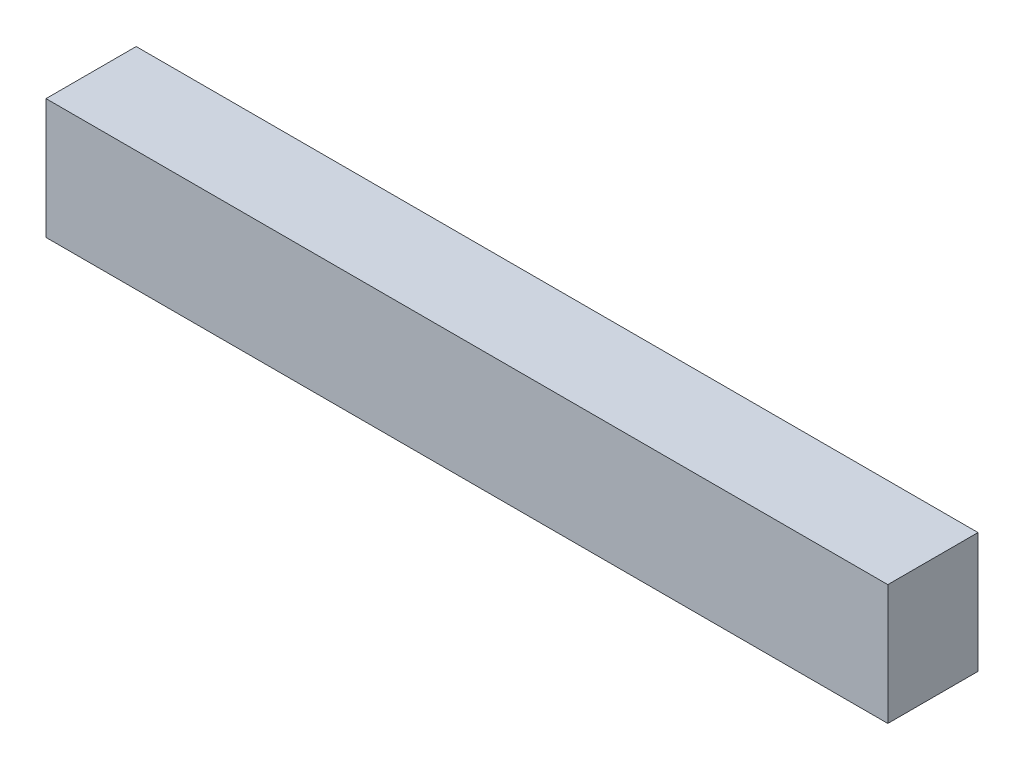
from build123d import *

# Parameters (mm, degrees)
SKETCH1_W           = 28
SKETCH1_H           = 4
BOSS_EXTRUDE1_DEPTH = 3


with BuildPart() as part:
    # Sketch1 → Boss-Extrude1 (new body)
    with BuildSketch(Plane.XY):
        with Locations((-46.840548194, -19.554839833)):
            Rectangle(SKETCH1_W, SKETCH1_H)
    extrude(amount=BOSS_EXTRUDE1_DEPTH)


solid = part.part
